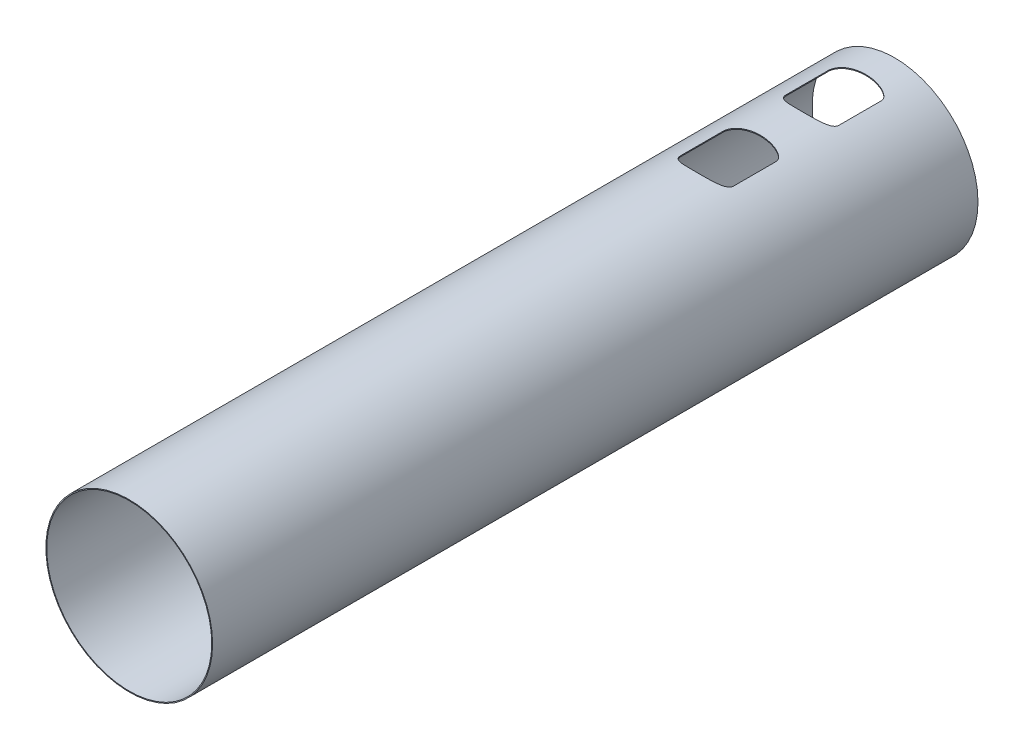
from build123d import *

# Parameters (mm, degrees)
SKETCH1_R           = 118.75
SKETCH1_R_2         = 117.5
EXTRUDE1_DEPTH      = 540
EXTRUDE1_DEPTH_BACK = 550
EXTRUDE2_DEPTH      = 119.75
EXTRUDE3_DEPTH      = 183


with BuildPart() as part:
    # Sketch1 → Extrude1 (new body, two sides)
    with BuildSketch(Plane.XY) as extrude1_sk:
        Circle(SKETCH1_R)
        Circle(SKETCH1_R_2, mode=Mode.SUBTRACT)
    extrude(amount=EXTRUDE1_DEPTH)
    extrude(extrude1_sk.sketch, amount=-EXTRUDE1_DEPTH_BACK)

    # Sketch2 → Extrude2 (cut, through all)
    with BuildSketch(Plane(origin=(0, 0, 0), x_dir=(1, 0, 0), z_dir=(0, 1, 0))):
        with BuildLine():
            Line((-37.607549402, 493.543681834), (-37.607549402, 432.856318166))
            add(Edge.make_bspline(
                [(-37.607549402, 432.856318166), (-37.607549402, 432.000385927), (-37.468288677, 431.169487784), (-37.069352881, 429.957303812), (-36.90536527, 429.561828888), (-36.52889093, 428.804146377), (-36.315262577, 428.439181434), (-35.842769351, 427.733973361), (-35.583352365, 427.393060576), (-35.03696833, 426.747214494), (-34.748443401, 426.440376443), (-33.843645583, 425.561009209), (-33.188884815, 425.028178809), (-31.801935904, 424.046478984), (-31.083509564, 423.606860233), (-29.609854098, 422.803186135), (-28.854724205, 422.438927044), (-26.546059173, 421.435002641), (-24.945906924, 420.881135812), (-23.3224362, 420.4108942)],
                knots=[0, 0, 0, 0, 0.125, 0.125, 0.1875, 0.1875, 0.25, 0.25, 0.3125, 0.3125, 0.375, 0.375, 0.5, 0.5, 0.625, 0.625, 0.75, 0.75, 1, 1, 1, 1], degree=3))
            add(Edge.make_bspline(
                [(-23.3224362, 420.4108942), (-21.427908645, 419.862140425), (-19.511788175, 419.429393725), (-15.650462776, 418.720155406), (-13.70507571, 418.444642318), (-9.791704072, 418.015020328), (-7.830187608, 417.861911571), (-3.903933315, 417.659893455), (-1.938303692, 417.610995824), (1.997700387, 417.612006674), (3.96294475, 417.661984508), (7.87761336, 417.865323233), (9.82858083, 418.018564496), (13.715546117, 418.446302475), (15.651587901, 418.720443062), (19.504022007, 419.427886536), (21.420559715, 419.860011792), (23.322436199, 420.4108942)],
                knots=[0, 0, 0, 0, 0.125, 0.125, 0.25, 0.25, 0.375, 0.375, 0.5, 0.5, 0.625, 0.625, 0.75, 0.75, 0.875, 0.875, 1, 1, 1, 1], degree=3))
            add(Edge.make_bspline(
                [(23.322436199, 420.4108942), (24.946148364, 420.881205745), (26.540086164, 421.43218612), (28.863076092, 422.442666213), (29.626042575, 422.811228846), (31.102256551, 423.617952024), (31.817706549, 424.057133686), (32.846589321, 424.785930969), (33.182020251, 425.040768109), (33.835191843, 425.578410214), (34.153402971, 425.861670029), (35.061623535, 426.746598375), (35.610948747, 427.386354185), (36.556462524, 428.801681507), (36.935245247, 429.552695935), (37.33068237, 430.750308916), (37.434167505, 431.16508755), (37.572267334, 432.005382442), (37.607549402, 432.429024595), (37.607549402, 432.856318166)],
                knots=[0, 0, 0, 0, 0.25, 0.25, 0.375, 0.375, 0.5, 0.5, 0.5625, 0.5625, 0.625, 0.625, 0.75, 0.75, 0.875, 0.875, 0.9375, 0.9375, 1, 1, 1, 1], degree=3))
            Line((37.607549402, 432.856318166), (37.607549402, 493.543681834))
            add(Edge.make_bspline(
                [(37.607549402, 493.543681834), (37.607549402, 494.399630005), (37.467948812, 495.230573926), (37.069263077, 496.443086472), (36.905131755, 496.838356992), (36.528306853, 497.595828964), (36.314710825, 497.960853306), (35.842487632, 498.666383994), (35.583143456, 499.007237344), (35.036666344, 499.652669697), (34.748130691, 499.959397755), (33.843686915, 500.838990725), (33.188691188, 501.372302724), (31.801985357, 502.353437913), (31.083665486, 502.792952558), (29.610194783, 503.596669134), (28.855067587, 503.960919396), (26.54628093, 504.964914599), (24.945905152, 505.518864702), (23.322436199, 505.9891058)],
                knots=[0, 0, 0, 0, 0.125, 0.125, 0.1875, 0.1875, 0.25, 0.25, 0.3125, 0.3125, 0.375, 0.375, 0.5, 0.5, 0.625, 0.625, 0.75, 0.75, 1, 1, 1, 1], degree=3))
            add(Edge.make_bspline(
                [(23.322436199, 505.9891058), (21.427907774, 506.537859827), (19.511783938, 506.970593451), (15.650461589, 507.679858254), (13.705069316, 507.955348464), (9.791699407, 508.384990007), (7.830180637, 508.538073306), (3.903927043, 508.740122644), (1.938295476, 508.788988351), (-1.997707902, 508.78800964), (-3.962948938, 508.737997751), (-7.877620714, 508.534694534), (-9.828584397, 508.38142759), (-13.715550318, 507.953704906), (-15.651589107, 507.679545225), (-19.504024728, 506.972124573), (-21.420560376, 506.539988016), (-23.3224362, 505.9891058)],
                knots=[0, 0, 0, 0, 0.125, 0.125, 0.25, 0.25, 0.375, 0.375, 0.5, 0.5, 0.625, 0.625, 0.75, 0.75, 0.875, 0.875, 1, 1, 1, 1], degree=3))
            add(Edge.make_bspline(
                [(-23.3224362, 505.9891058), (-24.945828081, 505.518887026), (-26.540003634, 504.967910196), (-28.864434329, 503.956710108), (-29.624468389, 503.589391651), (-31.094206724, 502.786748592), (-31.805579505, 502.35036341), (-33.167820476, 501.387302059), (-33.818823039, 500.860826413), (-34.732034796, 499.976662177), (-35.026613205, 499.664284792), (-35.576291185, 499.016003725), (-35.833232364, 498.679026314), (-36.306111822, 497.975662904), (-36.522292442, 497.608183304), (-36.903871533, 496.842107673), (-37.06607219, 496.450660187), (-37.330803649, 495.650212806), (-37.433076595, 495.24113706), (-37.571650597, 494.403579363), (-37.607549402, 493.97323797), (-37.607549402, 493.543681834)],
                knots=[0, 0, 0, 0, 0.25, 0.25, 0.375, 0.375, 0.5, 0.5, 0.625, 0.625, 0.6875, 0.6875, 0.75, 0.75, 0.8125, 0.8125, 0.875, 0.875, 0.9375, 0.9375, 1, 1, 1, 1], degree=3))
        make_face()
        with BuildLine():
            Line((-37.607549402, 343.543681834), (-37.607549402, 282.856318166))
            add(Edge.make_bspline(
                [(-37.607549402, 282.856318166), (-37.607549402, 282.000385927), (-37.468288677, 281.169487784), (-37.069352881, 279.957303812), (-36.90536527, 279.561828888), (-36.52889093, 278.804146377), (-36.315262577, 278.439181434), (-35.842769351, 277.733973361), (-35.583352365, 277.393060576), (-35.03696833, 276.747214494), (-34.748443401, 276.440376443), (-33.843645583, 275.561009209), (-33.188884814, 275.028178809), (-31.801935904, 274.046478984), (-31.083509564, 273.606860232), (-29.609854097, 272.803186135), (-28.854724205, 272.438927044), (-26.546059173, 271.435002641), (-24.945906924, 270.881135811), (-23.322436199, 270.4108942)],
                knots=[0, 0, 0, 0, 0.125, 0.125, 0.1875, 0.1875, 0.25, 0.25, 0.3125, 0.3125, 0.375, 0.375, 0.5, 0.5, 0.625, 0.625, 0.75, 0.75, 1, 1, 1, 1], degree=3))
            add(Edge.make_bspline(
                [(-23.322436199, 270.4108942), (-21.427908645, 269.862140425), (-19.511788175, 269.429393725), (-15.650462776, 268.720155406), (-13.70507571, 268.444642318), (-9.791704072, 268.015020328), (-7.830187608, 267.861911571), (-3.903933315, 267.659893455), (-1.938303692, 267.610995824), (1.997700387, 267.612006674), (3.96294475, 267.661984508), (7.87761336, 267.865323233), (9.82858083, 268.018564496), (13.715546117, 268.446302475), (15.651587901, 268.720443062), (19.504022008, 269.427886536), (21.420559715, 269.860011792), (23.322436199, 270.4108942)],
                knots=[0, 0, 0, 0, 0.125, 0.125, 0.25, 0.25, 0.375, 0.375, 0.5, 0.5, 0.625, 0.625, 0.75, 0.75, 0.875, 0.875, 1, 1, 1, 1], degree=3))
            add(Edge.make_bspline(
                [(23.322436199, 270.4108942), (24.946148364, 270.881205745), (26.540086164, 271.43218612), (28.863076093, 272.442666213), (29.626042575, 272.811228846), (31.102256551, 273.617952023), (31.81770655, 274.057133686), (32.846589321, 274.785930969), (33.182020251, 275.040768108), (33.835191843, 275.578410214), (34.153402971, 275.861670029), (35.061623535, 276.746598375), (35.610948747, 277.386354185), (36.556462525, 278.801681507), (36.935245247, 279.552695935), (37.33068237, 280.750308916), (37.434167505, 281.165087549), (37.572267334, 282.005382442), (37.607549402, 282.429024595), (37.607549402, 282.856318166)],
                knots=[0, 0, 0, 0, 0.25, 0.25, 0.375, 0.375, 0.5, 0.5, 0.5625, 0.5625, 0.625, 0.625, 0.75, 0.75, 0.875, 0.875, 0.9375, 0.9375, 1, 1, 1, 1], degree=3))
            Line((37.607549402, 282.856318166), (37.607549402, 343.543681834))
            add(Edge.make_bspline(
                [(37.607549402, 343.543681834), (37.607549402, 344.399630005), (37.467948812, 345.230573926), (37.069263077, 346.443086472), (36.905131755, 346.838356992), (36.528306853, 347.595828963), (36.314710825, 347.960853306), (35.842487632, 348.666383994), (35.583143456, 349.007237344), (35.036666345, 349.652669697), (34.748130691, 349.959397755), (33.843686915, 350.838990725), (33.188691188, 351.372302724), (31.801985357, 352.353437913), (31.083665486, 352.792952557), (29.610194783, 353.596669134), (28.855067587, 353.960919396), (26.54628093, 354.964914599), (24.945905152, 355.518864702), (23.322436199, 355.9891058)],
                knots=[0, 0, 0, 0, 0.125, 0.125, 0.1875, 0.1875, 0.25, 0.25, 0.3125, 0.3125, 0.375, 0.375, 0.5, 0.5, 0.625, 0.625, 0.75, 0.75, 1, 1, 1, 1], degree=3))
            add(Edge.make_bspline(
                [(23.322436199, 355.9891058), (21.427907774, 356.537859827), (19.511783938, 356.970593451), (15.650461589, 357.679858253), (13.705069316, 357.955348464), (9.791699407, 358.384990007), (7.830180637, 358.538073305), (3.903927043, 358.740122644), (1.938295476, 358.788988351), (-1.997707902, 358.78800964), (-3.962948938, 358.737997751), (-7.877620714, 358.534694533), (-9.828584397, 358.38142759), (-13.715550318, 357.953704906), (-15.651589107, 357.679545225), (-19.504024728, 356.972124573), (-21.420560376, 356.539988016), (-23.322436199, 355.9891058)],
                knots=[0, 0, 0, 0, 0.125, 0.125, 0.25, 0.25, 0.375, 0.375, 0.5, 0.5, 0.625, 0.625, 0.75, 0.75, 0.875, 0.875, 1, 1, 1, 1], degree=3))
            add(Edge.make_bspline(
                [(-23.322436199, 355.9891058), (-24.945828081, 355.518887026), (-26.540003634, 354.967910196), (-28.864434329, 353.956710108), (-29.624468389, 353.589391651), (-31.094206724, 352.786748592), (-31.805579505, 352.35036341), (-33.167820476, 351.387302059), (-33.818823039, 350.860826413), (-34.732034796, 349.976662177), (-35.026613205, 349.664284792), (-35.576291185, 349.016003725), (-35.833232364, 348.679026314), (-36.306111822, 347.975662904), (-36.522292442, 347.608183304), (-36.903871533, 346.842107673), (-37.06607219, 346.450660187), (-37.330803649, 345.650212805), (-37.433076595, 345.24113706), (-37.571650597, 344.403579363), (-37.607549402, 343.97323797), (-37.607549402, 343.543681834)],
                knots=[0, 0, 0, 0, 0.25, 0.25, 0.375, 0.375, 0.5, 0.5, 0.625, 0.625, 0.6875, 0.6875, 0.75, 0.75, 0.8125, 0.8125, 0.875, 0.875, 0.9375, 0.9375, 1, 1, 1, 1], degree=3))
        make_face()
    extrude(amount=EXTRUDE2_DEPTH, mode=Mode.SUBTRACT)

    # Sketch3 → Extrude3 (cut)
    with BuildSketch(Plane(origin=(0, 0, 0), x_dir=(1, 0, 0), z_dir=(0, 1, 0))):
        with BuildLine():
            Line((37.607549402, 357.856318166), (37.607549402, 418.543681834))
            add(Edge.make_bspline(
                [(37.607549402, 418.543681834), (37.607549402, 419.399614073), (37.468288677, 420.230512216), (37.069352881, 421.442696188), (36.90536527, 421.838171112), (36.52889093, 422.595853623), (36.315262577, 422.960818566), (35.842769351, 423.666026639), (35.583352365, 424.006939424), (35.03696833, 424.652785506), (34.748443401, 424.959623557), (33.843645583, 425.838990791), (33.188884814, 426.371821191), (31.801935904, 427.353521016), (31.083509564, 427.793139767), (29.609854097, 428.596813865), (28.854724205, 428.961072956), (26.546059173, 429.964997359), (24.945906924, 430.518864188), (23.322436199, 430.9891058)],
                knots=[0, 0, 0, 0, 0.125, 0.125, 0.1875, 0.1875, 0.25, 0.25, 0.3125, 0.3125, 0.375, 0.375, 0.5, 0.5, 0.625, 0.625, 0.75, 0.75, 1, 1, 1, 1], degree=3))
            add(Edge.make_bspline(
                [(23.322436199, 430.9891058), (21.427908645, 431.537859575), (19.511788175, 431.970606275), (15.650462776, 432.679844594), (13.70507571, 432.955357682), (9.791704072, 433.384979672), (7.830187608, 433.538088429), (3.903933315, 433.740106545), (1.938303692, 433.789004176), (-1.997700387, 433.787993326), (-3.96294475, 433.738015492), (-7.87761336, 433.534676767), (-9.82858083, 433.381435504), (-13.715546117, 432.953697525), (-15.651587901, 432.679556938), (-19.504022007, 431.972113464), (-21.420559715, 431.539988208), (-23.322436199, 430.9891058)],
                knots=[0, 0, 0, 0, 0.125, 0.125, 0.25, 0.25, 0.375, 0.375, 0.5, 0.5, 0.625, 0.625, 0.75, 0.75, 0.875, 0.875, 1, 1, 1, 1], degree=3))
            add(Edge.make_bspline(
                [(-23.322436199, 430.9891058), (-24.946148364, 430.518794255), (-26.540086164, 429.96781388), (-28.863076093, 428.957333787), (-29.626042575, 428.588771154), (-31.102256551, 427.782047976), (-31.81770655, 427.342866314), (-32.846589321, 426.614069031), (-33.182020251, 426.359231891), (-33.835191843, 425.821589786), (-34.153402971, 425.538329971), (-35.061623535, 424.653401625), (-35.610948747, 424.013645815), (-36.556462524, 422.598318493), (-36.935245247, 421.847304065), (-37.33068237, 420.649691084), (-37.434167505, 420.23491245), (-37.572267334, 419.394617558), (-37.607549402, 418.970975405), (-37.607549402, 418.543681834)],
                knots=[0, 0, 0, 0, 0.25, 0.25, 0.375, 0.375, 0.5, 0.5, 0.5625, 0.5625, 0.625, 0.625, 0.75, 0.75, 0.875, 0.875, 0.9375, 0.9375, 1, 1, 1, 1], degree=3))
            Line((-37.607549402, 418.543681834), (-37.607549402, 357.856318166))
            add(Edge.make_bspline(
                [(-37.607549402, 357.856318166), (-37.607549402, 357.000369995), (-37.467948812, 356.169426074), (-37.069263077, 354.956913528), (-36.905131755, 354.561643008), (-36.528306853, 353.804171036), (-36.314710825, 353.439146694), (-35.842487632, 352.733616006), (-35.583143456, 352.392762656), (-35.036666345, 351.747330303), (-34.748130691, 351.440602245), (-33.843686915, 350.561009275), (-33.188691188, 350.027697276), (-31.801985357, 349.046562087), (-31.083665486, 348.607047442), (-29.610194783, 347.803330866), (-28.855067587, 347.439080604), (-26.54628093, 346.435085401), (-24.945905152, 345.881135298), (-23.322436199, 345.4108942)],
                knots=[0, 0, 0, 0, 0.125, 0.125, 0.1875, 0.1875, 0.25, 0.25, 0.3125, 0.3125, 0.375, 0.375, 0.5, 0.5, 0.625, 0.625, 0.75, 0.75, 1, 1, 1, 1], degree=3))
            add(Edge.make_bspline(
                [(-23.322436199, 345.4108942), (-21.427907774, 344.862140173), (-19.511783938, 344.429406549), (-15.650461589, 343.720141746), (-13.705069316, 343.444651536), (-9.791699407, 343.015009993), (-7.830180637, 342.861926694), (-3.903927043, 342.659877356), (-1.938295476, 342.611011649), (1.997707902, 342.61199036), (3.962948938, 342.662002249), (7.877620714, 342.865305466), (9.828584397, 343.01857241), (13.715550318, 343.446295094), (15.651589107, 343.720454775), (19.504024728, 344.427875427), (21.420560376, 344.860011984), (23.322436199, 345.4108942)],
                knots=[0, 0, 0, 0, 0.125, 0.125, 0.25, 0.25, 0.375, 0.375, 0.5, 0.5, 0.625, 0.625, 0.75, 0.75, 0.875, 0.875, 1, 1, 1, 1], degree=3))
            add(Edge.make_bspline(
                [(23.322436199, 345.4108942), (24.945828081, 345.881112974), (26.540003634, 346.432089804), (28.864434329, 347.443289892), (29.624468389, 347.810608349), (31.094206724, 348.613251408), (31.805579505, 349.04963659), (33.167820476, 350.012697941), (33.818823039, 350.539173587), (34.732034796, 351.423337823), (35.026613205, 351.735715208), (35.576291185, 352.383996275), (35.833232364, 352.720973686), (36.306111822, 353.424337096), (36.522292442, 353.791816696), (36.903871533, 354.557892327), (37.06607219, 354.949339813), (37.330803649, 355.749787194), (37.433076595, 356.15886294), (37.571650597, 356.996420637), (37.607549402, 357.42676203), (37.607549402, 357.856318166)],
                knots=[0, 0, 0, 0, 0.25, 0.25, 0.375, 0.375, 0.5, 0.5, 0.625, 0.625, 0.6875, 0.6875, 0.75, 0.75, 0.8125, 0.8125, 0.875, 0.875, 0.9375, 0.9375, 1, 1, 1, 1], degree=3))
        make_face()
    extrude(amount=-EXTRUDE3_DEPTH, mode=Mode.SUBTRACT)


solid = part.part
